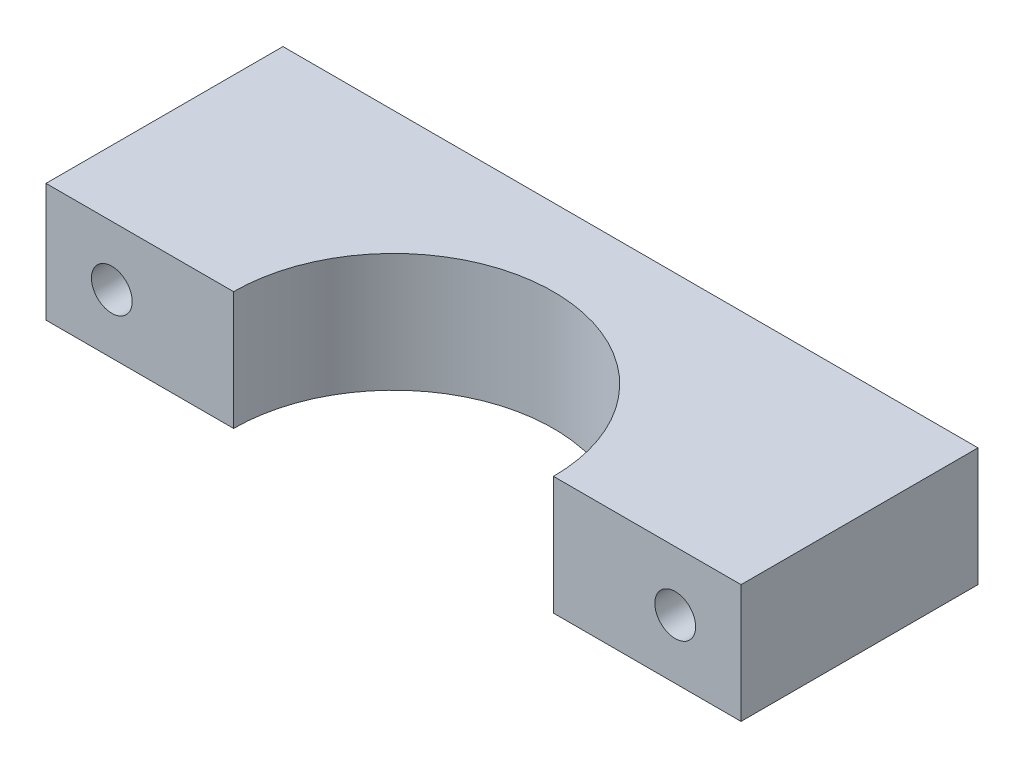
from build123d import *

# Parameters (mm, degrees)
BOSS_EXTRUDE1_DEPTH = 9
SKETCH2_R           = 1.55
CUT_EXTRUDE1_DEPTH  = 19


with BuildPart() as part:
    # Sketch1 → Boss-Extrude1 (new body)
    with BuildSketch(Plane(origin=(0, 0, 0), x_dir=(1, 0, 0), z_dir=(0, 1, 0))):
        with BuildLine():
            Line((12.15, 0), (26.4, 0))
            Line((26.4, 0), (26.4, 18))
            Line((26.4, 18), (-26.4, 18))
            Line((-26.4, 18), (-26.4, 0))
            Line((-26.4, 0), (-12.15, 0))
            ThreePointArc((-12.15, 0), (0, 12.15), (12.15, 0))
        make_face()
    extrude(amount=BOSS_EXTRUDE1_DEPTH)

    # Sketch2 → Cut-Extrude1 (cut, through all)
    with BuildSketch(Plane.XY):
        with Locations((21.4, 4.5)):
            Circle(SKETCH2_R)
    cut_extrude1 = extrude(amount=-CUT_EXTRUDE1_DEPTH, mode=Mode.SUBTRACT)

    # Mirror1: Cut-Extrude1 across plane
    add(cut_extrude1.mirror(Plane(origin=(0, 0, 0), x_dir=(0, 0, 1), z_dir=(1, 0, 0))), mode=Mode.SUBTRACT)


solid = part.part
